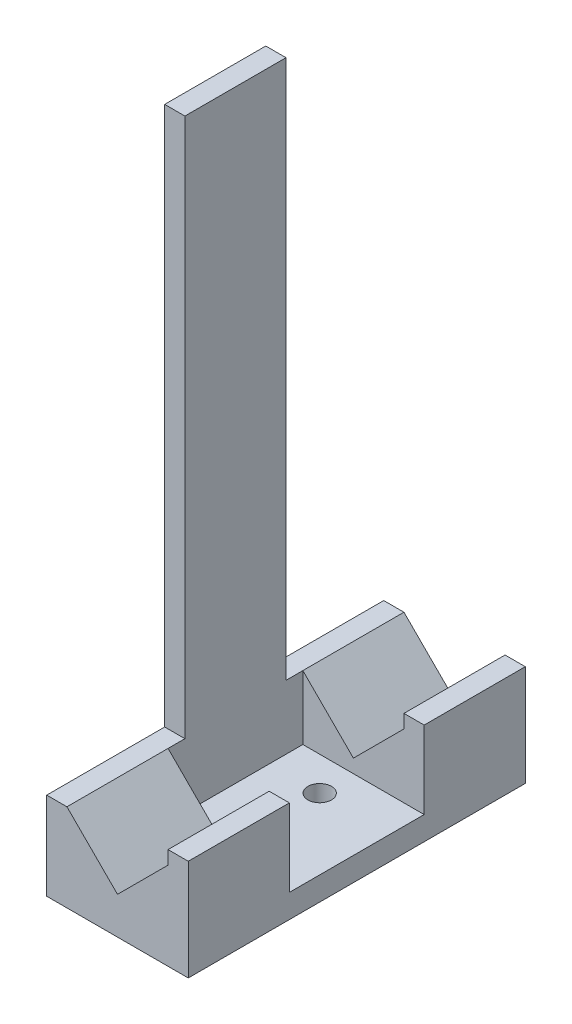
from build123d import *

# Parameters (mm, degrees)
RESSALTO_EXTRUS_O1_DEPTH   = 50
ESBO_O3_W                  = 6
ESBO_O3_H                  = 17.5
CORTE_EXTRUS_O2_DEPTH      = 80
ESBO_O4_W                  = 20
ESBO_O4_H                  = 11.5
CORTE_EXTRUS_O3_DEPTH      = 18
ESBO_O5_R                  = 1.75
ESBO_O5_W                  = 3
ESBO_O5_H                  = 22.5
CORTE_EXTRUS_O4_DEPTH      = 90.5
CORTE_EXTRUS_O4_DEPTH_BACK = 4.5


with BuildPart() as part:
    # Esboço1 → Ressalto-extrusão1 (new body)
    with BuildSketch(Plane.XY):
        Polygon((21, 0), (0, 0), (0, 4), (-2, 1), (-3, 1), (-3, 4), (0, 8.5), (0, 93), (3, 93), (3, 13), (10.5, 5.5), (18, 13), (18, 15), (21, 15), align=None)
    extrude(amount=RESSALTO_EXTRUS_O1_DEPTH)

    # Esboço3 → Corte-extrusão2 (cut)
    with BuildSketch(Plane(origin=(0, 93, 0), x_dir=(1, 0, 0), z_dir=(0, 1, 0))):
        with Locations((0, -8.75)):
            Rectangle(ESBO_O3_W, ESBO_O3_H)
        with Locations((0, -41.25)):
            Rectangle(ESBO_O3_W, ESBO_O3_H)
    extrude(amount=-CORTE_EXTRUS_O2_DEPTH, mode=Mode.SUBTRACT)

    # Esboço4 → Corte-extrusão3 (cut)
    with BuildSketch(Plane(origin=(21, 0, 0), x_dir=(0, 0, -1), z_dir=(1, 0, 0))):
        with Locations((-25, 9.25)):
            Rectangle(ESBO_O4_W, ESBO_O4_H)
    extrude(amount=-CORTE_EXTRUS_O3_DEPTH, mode=Mode.SUBTRACT)

    # Esboço5 → Corte-extrusão4 (cut, two sides)
    with BuildSketch(Plane(origin=(0, 3.5, 0), x_dir=(1, 0, 0), z_dir=(0, 1, 0))) as corte_extrus_o4_sk:
        with Locations((10.5, -20)):
            Circle(ESBO_O5_R)
        with Locations((10.5, -30)):
            Circle(ESBO_O5_R)
        with Locations((-1.5, -11.25)):
            Rectangle(ESBO_O5_W, ESBO_O5_H)
        with Locations((-1.5, -38.75)):
            Rectangle(ESBO_O5_W, ESBO_O5_H)
    extrude(amount=CORTE_EXTRUS_O4_DEPTH, mode=Mode.SUBTRACT)
    extrude(corte_extrus_o4_sk.sketch, amount=-CORTE_EXTRUS_O4_DEPTH_BACK, mode=Mode.SUBTRACT)


solid = part.part
